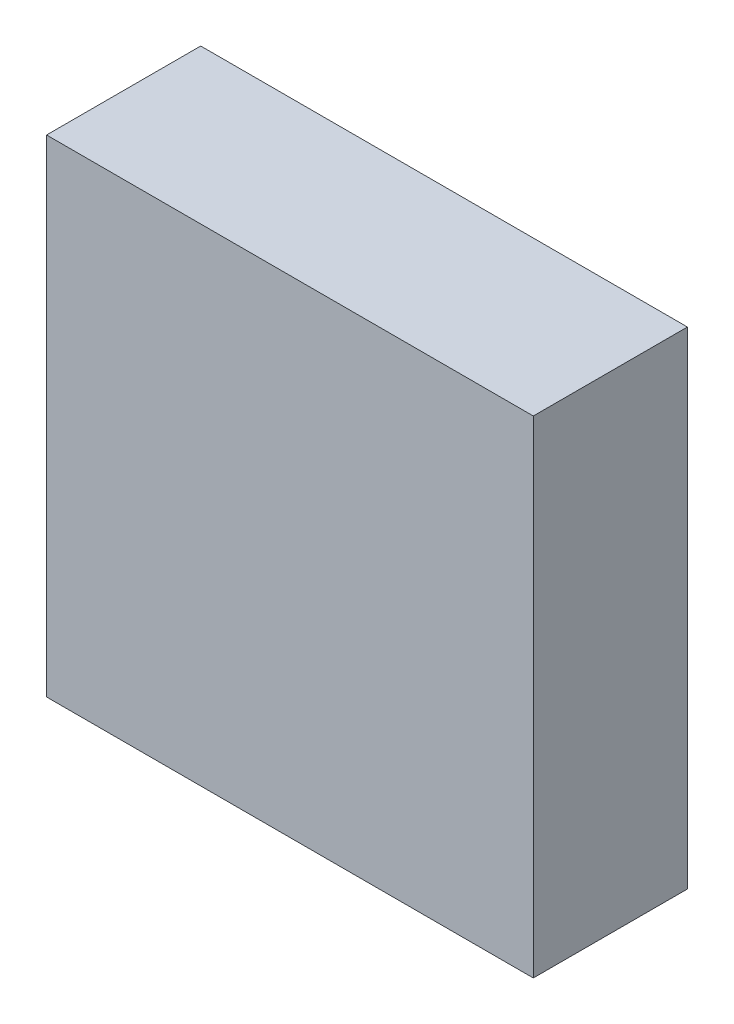
from build123d import *

# Parameters (mm, degrees)
SKETCH1_W           = 15
SKETCH1_H           = 15
BOSS_EXTRUDE1_DEPTH = 4.75


with BuildPart() as part:
    # Sketch1 → Boss-Extrude1 (new body)
    with BuildSketch(Plane.XY):
        with Locations((7.5, 7.5)):
            Rectangle(SKETCH1_W, SKETCH1_H)
    extrude(amount=BOSS_EXTRUDE1_DEPTH)


solid = part.part
